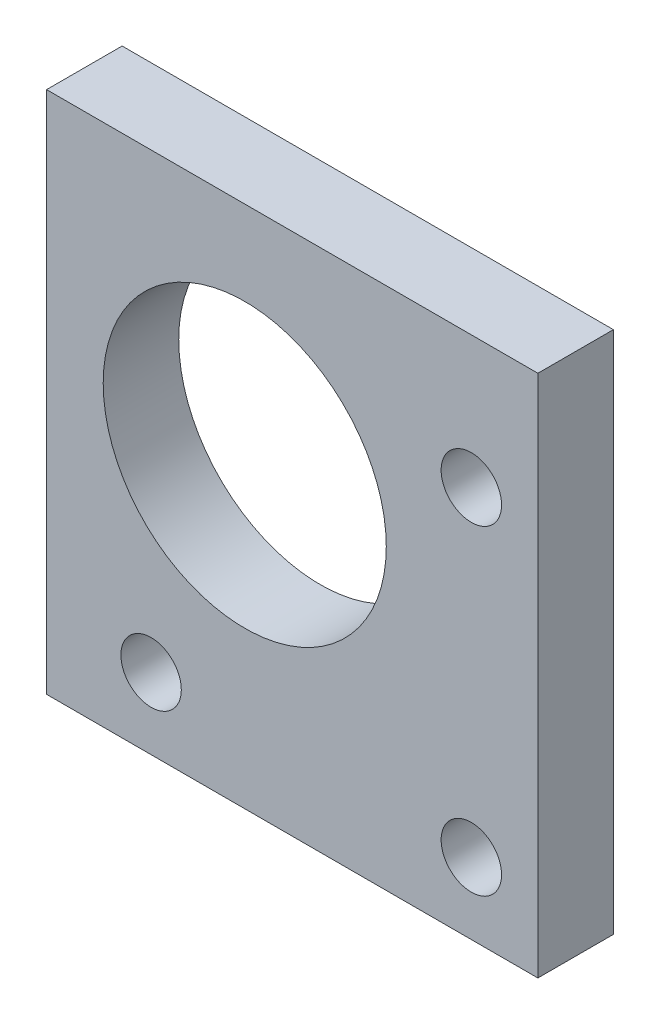
from build123d import *

# Parameters (mm, degrees)
SKETCH1_W           = 41.303343927
SKETCH1_H           = 44.031810838
SKETCH1_R           = 11.8999
SKETCH1_R_2         = 2.54
BOSS_EXTRUDE1_DEPTH = 6.35


with BuildPart() as part:
    # Sketch1 → Boss-Extrude1 (new body)
    with BuildSketch(Plane.XY):
        with Locations((3.992518762, -3.025665718)):
            Rectangle(SKETCH1_W, SKETCH1_H)
        Circle(SKETCH1_R, mode=Mode.SUBTRACT)
        with Locations((19.05, 7.874)):
            Circle(SKETCH1_R_2, mode=Mode.SUBTRACT)
        with Locations((19.05, -19.05)):
            Circle(SKETCH1_R_2, mode=Mode.SUBTRACT)
        with Locations((-7.874, -19.05)):
            Circle(SKETCH1_R_2, mode=Mode.SUBTRACT)
    extrude(amount=BOSS_EXTRUDE1_DEPTH)


solid = part.part
